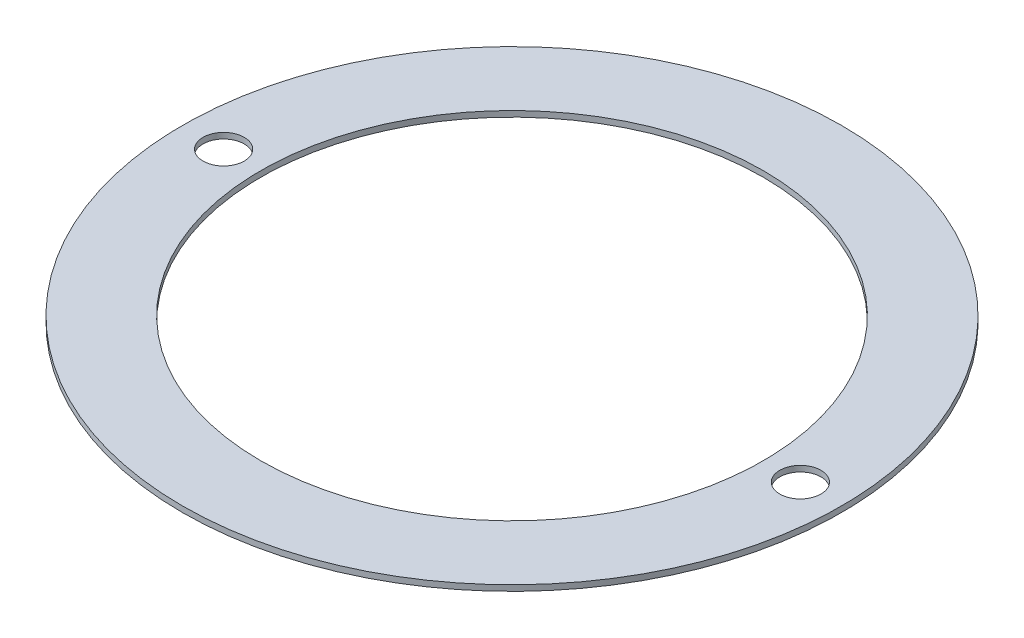
from build123d import *

# Parameters (mm, degrees)
SKETCH1_R                    = 8
SKETCH1_R_2                  = 6.1
BOSS_EXTRUDE1_DEPTH          = 0.14
F_1_0_1_DIAMETER_HOLE1_D     = 1
F_1_0_1_DIAMETER_HOLE1_DEPTH = 0.14


with BuildPart() as part:
    # Sketch1 → Boss-Extrude1 (new body)
    with BuildSketch(Plane(origin=(0, 0, 0), x_dir=(1, 0, 0), z_dir=(0, 1, 0))):
        Circle(SKETCH1_R)
        Circle(SKETCH1_R_2, mode=Mode.SUBTRACT)
    extrude(amount=BOSS_EXTRUDE1_DEPTH)

    # Ø1.0 (1) Diameter Hole1
    with Locations(Plane(origin=(0, 0.14, 0), x_dir=(1, 0, 0), z_dir=(0, 1, 0))):
        with Locations((-7, 0), (7, 0)):
            Hole(F_1_0_1_DIAMETER_HOLE1_D / 2, depth=F_1_0_1_DIAMETER_HOLE1_DEPTH)


solid = part.part
